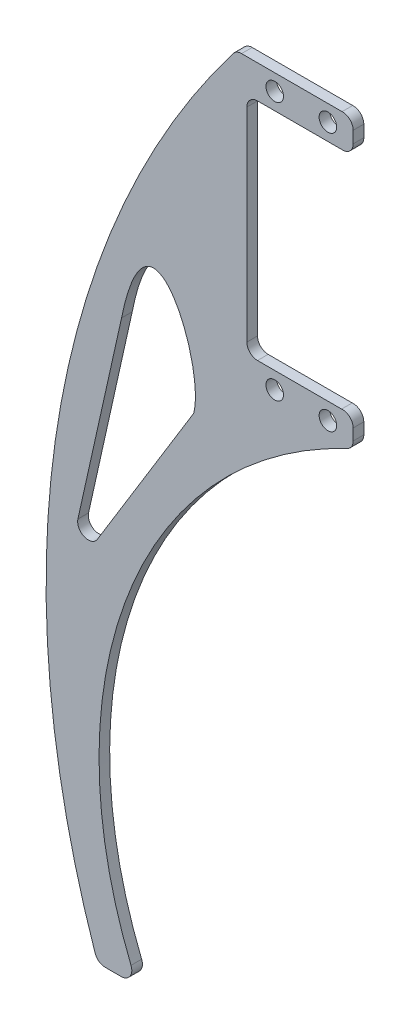
from build123d import *

# Parameters (mm, degrees)
EXTRUDE_1_DEPTH     = 2
SKETCH_2_R          = 1.65
CUT_EXTRUDE_1_DEPTH = 3.0000001


with BuildPart() as part:
    # 草图1 → 凸台-拉伸1 (new body)
    with BuildSketch(Plane.XY):
        with BuildLine():
            Line((1.423252987, 0), (4.423252987, 0))
            ThreePointArc((4.423252987, 0), (6.082636631, 0.883556575), (6.275860947, 2.753554078))
            ThreePointArc((6.275860947, 2.753554078), (5.811551363, 63.103247136), (46.929512186, 107.280326411))
            ThreePointArc((46.929512186, 107.280326411), (47.763039313, 108.018300592), (48.072882653, 109.087585618))
            Line((48.072882653, 109.087585618), (48.072882653, 111.207813928))
            ThreePointArc((48.072882653, 111.207813928), (47.423208509, 112.683151206), (45.89626257, 113.2))
            Line((45.89626257, 113.2), (30.072910523, 113.2))
            ThreePointArc((30.072910523, 113.2), (28.658696961, 113.785786438), (28.072910523, 115.2))
            Line((28.072910523, 115.2), (28.072910523, 153.5))
            ThreePointArc((28.072910523, 153.5), (28.658696961, 154.914213563), (30.072910523, 155.5))
            Line((30.072910523, 155.5), (46.202994429, 155.5))
            ThreePointArc((46.202994429, 155.5), (47.532372899, 156.128324681), (48.072882653, 157.495763244))
            Line((48.072882653, 157.495763244), (48.072882653, 159.708737404))
            ThreePointArc((48.072882653, 159.708737404), (47.455107078, 161.15423235), (45.983427014, 161.706735824))
            Line((45.983427014, 161.706735824), (27.073474975, 161.706735824))
            ThreePointArc((27.073474975, 161.706735824), (26.186750001, 161.499420632), (25.483856586, 160.920454645))
            ThreePointArc((25.483856586, 160.920454645), (-7.477274918, 84.38693582), (-0.469066984, 1.352601263))
            ThreePointArc((-0.469066984, 1.352601263), (0.260239117, 0.372917108), (1.423252987, 0))
        make_face()
        with BuildLine():
            Line((-3.714345647, 70.477818401), (4.498485812, 107.347765252))
            add(Edge.make_bspline(
                [(4.498485812, 107.347765252), (9.65057542, 132.963079711), (20.376969719, 107.570049249), (18.069358559, 98.588262366)],
                knots=[0, 0, 0, 0, 1, 1, 1, 1], degree=3))
            Line((18.069358559, 98.588262366), (-0.056738646, 68.998256027))
            ThreePointArc((-0.056738646, 68.998256027), (-2.512185077, 68.188921333), (-3.714345647, 70.477818401))
        make_face(mode=Mode.SUBTRACT)
    extrude(amount=EXTRUDE_1_DEPTH)

    # 草图2 → 切除-拉伸1 (cut, through all)
    with BuildSketch(Plane.XY.offset(2)):
        with Locations((43.316196674, 158.665)):
            Circle(SKETCH_2_R)
        with Locations((33.316196674, 158.665)):
            Circle(SKETCH_2_R)
        with Locations((43.316196674, 110.035)):
            Circle(SKETCH_2_R)
        with Locations((33.316196674, 110.035)):
            Circle(SKETCH_2_R)
    extrude(amount=-CUT_EXTRUDE_1_DEPTH, mode=Mode.SUBTRACT)


solid = part.part
